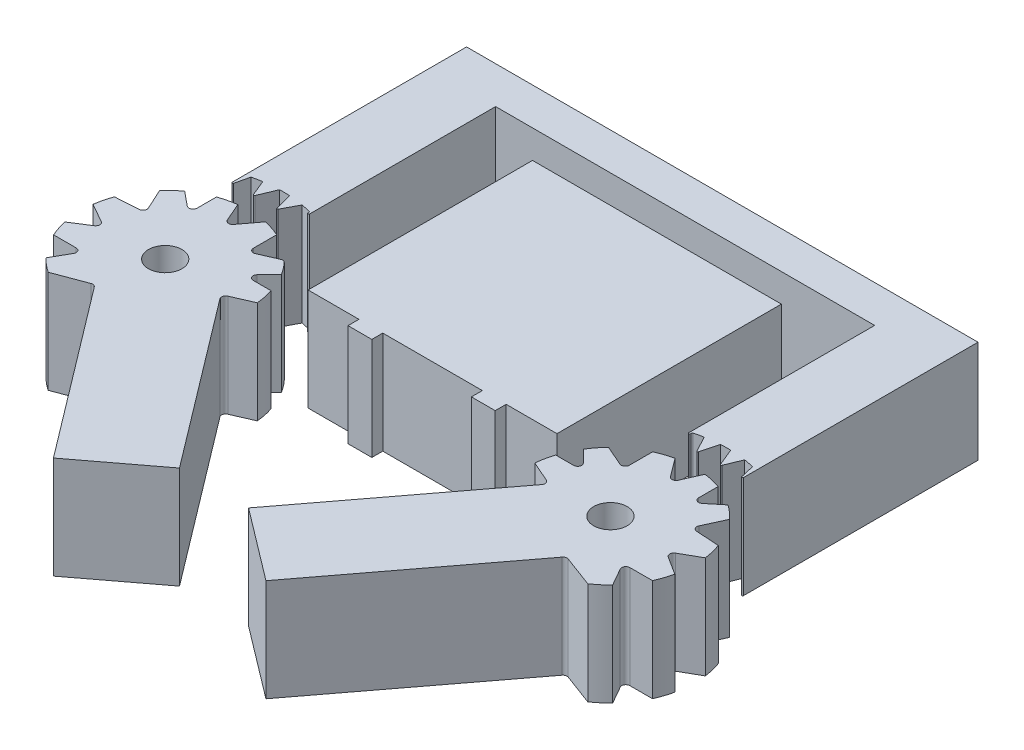
from build123d import *

# Parameters (mm, degrees)
BOSS_EXTRUDE1_DEPTH   = 10
SKETCH1_R             = 1.634862636
BOSS_EXTRUDE1_2_DEPTH = 10
BOSS_EXTRUDE1_3_DEPTH = 10
BOSS_EXTRUDE1_4_DEPTH = 10
FILLET3_R             = 0.08
FILLET4_R             = 0.4
FILLET5_R             = 0.4


with BuildPart() as part:
    # Sketch1 → Boss-Extrude1 (new body)
    with BuildSketch(Plane(origin=(0, 0, 0), x_dir=(1, 0, 0), z_dir=(0, 1, 0))):
        Polygon((37.164723878, 48.612251684), (37.164723878, 26.675451349), (32.195744528, 26.675451349), (32.195744528, 25.605091118), (29.866967358, 25.605091118), (29.866967358, 26.675451349), (20.133032642, 26.675451349), (20.133032642, 25.605091118), (17.804255472, 25.605091118), (17.804255472, 26.675451349), (12.835276122, 26.675451349), (12.835276122, 48.612251684), align=None)
    extrude(amount=BOSS_EXTRUDE1_DEPTH)


with BuildPart() as body_2:
    # Sketch1 → Boss-Extrude1 2 (new body)
    with BuildSketch(Plane(origin=(0, 0, 0), x_dir=(1, 0, 0), z_dir=(0, 1, 0))):
        with BuildLine():
            Line((-1.38016006, 18.901152594), (-2.700358537, 16.585087375))
            ThreePointArc((-2.700358537, 16.585087375), (-2.068010706, 15.993904553), (-1.377138562, 15.472314112))
            Line((-1.377138562, 15.472314112), (1.951668945, 16.713640495))
            Line((1.951668945, 16.713640495), (14.612447645, 0))
            Line((14.612447645, 0), (21.623536668, 5.310982164))
            Line((21.623536668, 5.310982164), (8.962757967, 22.024622659))
            Line((8.962757967, 22.024622659), (11.437701272, 23.107681531))
            ThreePointArc((11.437701272, 23.107681531), (11.307856053, 23.963544328), (11.088950356, 24.801065196))
            Line((11.088950356, 24.801065196), (8.395715441, 24.801065196))
            Line((8.395715441, 24.801065196), (10.220537046, 26.675451349))
            ThreePointArc((10.220537046, 26.675451349), (9.723160987, 27.383955382), (9.154209441, 28.036377827))
            Line((9.154209441, 28.036377827), (6.621696735, 26.928126035))
            Line((6.621696735, 26.928126035), (6.621696735, 29.8147682))
            ThreePointArc((6.621696735, 29.8147682), (5.814872257, 30.128448245), (4.979595029, 30.355764897))
            Line((4.979595029, 30.355764897), (3.236149851, 28.034465682))
            Line((3.236149851, 28.034465682), (2.162614812, 30.472071154))
            ThreePointArc((2.162614812, 30.472071154), (1.31144171, 30.314383932), (0.481505188, 30.068281764))
            Line((0.481505188, 30.068281764), (0.481505188, 27.329349922))
            Line((0.481505188, 27.329349922), (-1.55963707, 29.003146704))
            ThreePointArc((-1.55963707, 29.003146704), (-2.236190449, 28.463112969), (-2.852363875, 27.855090587))
            Line((-2.852363875, 27.855090587), (-1.665080257, 25.275821099))
            Line((-1.665080257, 25.275821099), (-4.517323151, 25.093949256))
            ThreePointArc((-4.517323151, 25.093949256), (-4.767499265, 24.26523168), (-4.92936582, 23.414843459))
            Line((-4.92936582, 23.414843459), (-2.490458264, 22.024622659))
            Line((-2.490458264, 22.024622659), (-4.815054435, 20.542207918))
            ThreePointArc((-4.815054435, 20.542207918), (-4.586127349, 19.70737063), (-4.270891903, 18.901152594))
            Line((-4.270891903, 18.901152594), (-1.38016006, 18.901152594))
        make_face()
        with Locations((3.236149851, 22.301183348)):
            Circle(SKETCH1_R, mode=Mode.SUBTRACT)
    extrude(amount=BOSS_EXTRUDE1_2_DEPTH)

    # Fillet4
    fillet4_edges = [body_2.edges().sort_by_distance(p)[0] for p in [
        (-1.38016006, 5, -18.901152594),
        (-2.490458264, 5, -22.024622659),
        (-1.665080257, 5, -25.275821099),
        (0.481505188, 5, -27.329349922),
        (3.236149851, 5, -28.034465682),
        (6.621696735, 5, -26.928126035),
        (9.154209441, 5, -28.036377827),
        (8.395715441, 5, -24.801065196),
        (8.962757967, 5, -22.024622659),
        (1.951668945, 5, -16.713640495),
    ]]
    fillet(fillet4_edges, radius=FILLET4_R)


with BuildPart() as body_3:
    # Sketch1 → Boss-Extrude1 3 (new body)
    with BuildSketch(Plane(origin=(0, 0, 0), x_dir=(1, 0, 0), z_dir=(0, 1, 0))):
        with BuildLine():
            Line((43.703141587, 33.357527321), (43.527700297, 31.388462981))
            Line((43.527700297, 31.388462981), (43.527700297, 33.307454883))
            Line((43.527700297, 33.307454883), (43.527700297, 51.368312567))
            Line((43.527700297, 51.368312567), (6.472299703, 51.368312567))
            Line((6.472299703, 51.368312567), (6.472299703, 33.307454883))
            Line((6.472299703, 33.307454883), (6.472299703, 31.388462981))
            Line((6.472299703, 31.388462981), (6.296858413, 33.357527321))
            ThreePointArc((6.296858413, 33.357527321), (5.820283882, 33.478523384), (5.338962403, 33.578987138))
            Line((5.338962403, 33.578987138), (4.433036227, 31.872953299))
            Line((4.433036227, 31.872953299), (3.931055376, 33.752287455))
            ThreePointArc((3.931055376, 33.752287455), (3.439738349, 33.771546493), (2.948047339, 33.769734952))
            Line((2.948047339, 33.769734952), (2.162614812, 31.887571589))
            Line((2.162614812, 31.887571589), (1.445144074, 33.632687099))
            ThreePointArc((1.445144074, 33.632687099), (0.961235169, 33.545534914), (0.481505188, 33.437727324))
            Line((0.481505188, 33.437727324), (0, 31.388462981))
            Line((0, 31.388462981), (0, 33.307454883))
            Line((0, 33.307454883), (0, 55))
            Line((0, 55), (50, 55))
            Line((50, 55), (50, 31.388462981))
            Line((50, 31.388462981), (49.518494812, 33.437727324))
            ThreePointArc((49.518494812, 33.437727324), (49.038764831, 33.545534914), (48.554855926, 33.632687099))
            Line((48.554855926, 33.632687099), (47.837385188, 31.887571589))
            Line((47.837385188, 31.887571589), (47.051952661, 33.769734952))
            ThreePointArc((47.051952661, 33.769734952), (46.560261651, 33.771546493), (46.068944624, 33.752287455))
            Line((46.068944624, 33.752287455), (45.566963773, 31.872953299))
            Line((45.566963773, 31.872953299), (44.661037597, 33.578987138))
            ThreePointArc((44.661037597, 33.578987138), (44.179716118, 33.478523384), (43.703141587, 33.357527321))
        make_face()
    extrude(amount=BOSS_EXTRUDE1_3_DEPTH)

    # Fillet3
    fillet3_edges = [body_3.edges().sort_by_distance(p)[0] for p in [
        (43.527700297, 5, -31.388462981),
        (6.472299703, 5, -31.388462981),
        (4.433036227, 5, -31.872953299),
        (2.162614812, 5, -31.887571589),
        (0, 5, -31.388462981),
        (50, 5, -31.388462981),
        (47.837385188, 5, -31.887571589),
        (45.566963773, 5, -31.872953299),
        (43.703141587, 5, -33.357527321),
    ]]
    fillet(fillet3_edges, radius=FILLET3_R)


with BuildPart() as body_4:
    # Sketch1 → Boss-Extrude1 4 (new body)
    with BuildSketch(Plane(origin=(0, 0, 0), x_dir=(1, 0, 0), z_dir=(0, 1, 0))):
        with BuildLine():
            ThreePointArc((38.562298728, 23.107681531), (38.692143947, 23.963544328), (38.911049644, 24.801065196))
            Line((38.911049644, 24.801065196), (41.604284559, 24.801065196))
            Line((41.604284559, 24.801065196), (39.779462954, 26.675451349))
            ThreePointArc((39.779462954, 26.675451349), (40.276839013, 27.383955382), (40.845790559, 28.036377827))
            Line((40.845790559, 28.036377827), (43.378303265, 26.928126035))
            Line((43.378303265, 26.928126035), (43.378303265, 29.8147682))
            ThreePointArc((43.378303265, 29.8147682), (44.185127743, 30.128448245), (45.020404971, 30.355764897))
            Line((45.020404971, 30.355764897), (46.763850149, 28.034465682))
            Line((46.763850149, 28.034465682), (47.837385188, 30.472071154))
            ThreePointArc((47.837385188, 30.472071154), (48.68855829, 30.314383932), (49.518494812, 30.068281764))
            Line((49.518494812, 30.068281764), (49.518494812, 27.329349922))
            Line((49.518494812, 27.329349922), (51.55963707, 29.003146704))
            ThreePointArc((51.55963707, 29.003146704), (52.236190449, 28.463112969), (52.852363875, 27.855090587))
            Line((52.852363875, 27.855090587), (51.665080257, 25.275821099))
            Line((51.665080257, 25.275821099), (54.517323151, 25.093949256))
            ThreePointArc((54.517323151, 25.093949256), (54.767499265, 24.26523168), (54.92936582, 23.414843459))
            Line((54.92936582, 23.414843459), (52.490458264, 22.024622659))
            Line((52.490458264, 22.024622659), (54.815054435, 20.542207918))
            ThreePointArc((54.815054435, 20.542207918), (54.586127349, 19.70737063), (54.270891903, 18.901152594))
            Line((54.270891903, 18.901152594), (51.38016006, 18.901152594))
            Line((51.38016006, 18.901152594), (52.700358537, 16.585087375))
            ThreePointArc((52.700358537, 16.585087375), (52.068010706, 15.993904553), (51.377138562, 15.472314112))
            Line((51.377138562, 15.472314112), (48.048331055, 16.713640495))
            Line((48.048331055, 16.713640495), (35.387552355, 0))
            Line((35.387552355, 0), (28.376463332, 5.310982164))
            Line((28.376463332, 5.310982164), (41.037242033, 22.024622659))
            Line((41.037242033, 22.024622659), (38.562298728, 23.107681531))
        make_face()
        with Locations((46.763850149, 22.301183348)):
            Circle(SKETCH1_R, mode=Mode.SUBTRACT)
    extrude(amount=BOSS_EXTRUDE1_4_DEPTH)

    # Fillet5
    fillet5_edges = [body_4.edges().sort_by_distance(p)[0] for p in [
        (41.604284559, 5, -24.801065196),
        (43.378303265, 5, -26.928126035),
        (46.763850149, 5, -28.034465682),
        (49.518494812, 5, -27.329349922),
        (51.665080257, 5, -25.275821099),
        (52.490458264, 5, -22.024622659),
        (51.38016006, 5, -18.901152594),
        (48.048331055, 5, -16.713640495),
        (41.037242033, 5, -22.024622659),
    ]]
    fillet(fillet5_edges, radius=FILLET5_R)


solid = Compound([part.part, body_2.part, body_3.part, body_4.part])
